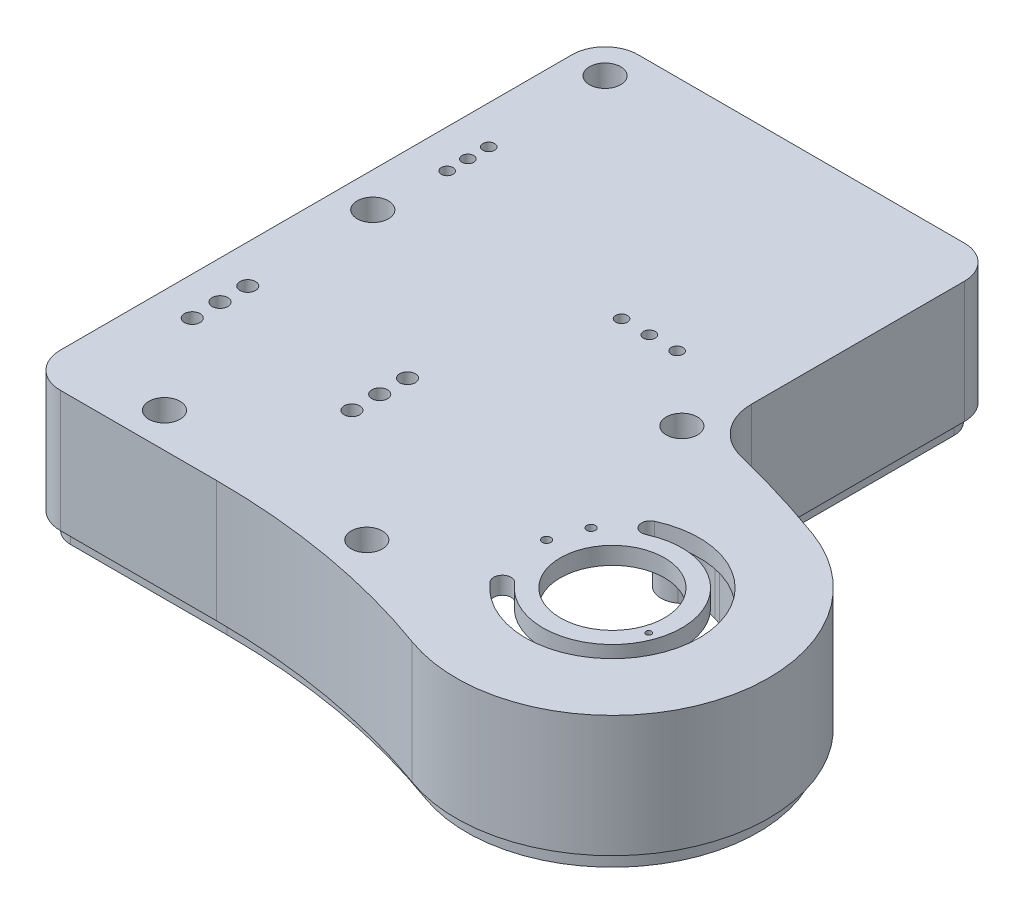
from build123d import *

# Parameters (mm, degrees)
EXTRUDE_1_DEPTH              = 35
CUT_EXTRUDE_1_DEPTH          = 30
CUT_EXTRUDE_2_REACH          = 37
SKETCH_3_R                   = 15
CUT_EXTRUDE_3_DEPTH          = 10
CUT_EXTRUDE_4_REACH          = 185.795
SKETCH_5_R                   = 15
SKETCH_5_R_2                 = 6.5
CUT_EXTRUDE_7_REACH          = 7
SKETCH_10_R                  = 1.7
SKETCH_13_R                  = 6
EXTRUDE_2_DEPTH              = 35
SKETCH_14_W                  = 2
SKETCH_14_H                  = 49.9
EXTRUDE_3_DEPTH              = 5
FILLET_1_R                   = 10
CUT_EXTRUDE_15_REACH         = 42
SKETCH_22_R                  = 1.7
SKETCH_22_R_2                = 2.25
SKETCH_23_R                  = 2.25
CUT_EXTRUDE_16_DEPTH         = 41.0000001
CUT_EXTRUDE_17_REACH         = 183.675
SKETCH_24_R                  = 1.2
HOLE_WIZARD_M4_1_D           = 4.5
HOLE_WIZARD_M4_1_DEPTH       = 40
HOLE_WIZARD_M4_1_CBORE_D     = 9
HOLE_WIZARD_M4_1_CBORE_DEPTH = 33.1
HOLE_WIZARD_M4_1_TIP         = 1.351936393
HOLE_WIZARD_M2_1_D           = 1.6
HOLE_WIZARD_M2_1_DEPTH       = 6
HOLE_WIZARD_M2_1_TIP         = 0.480688495
HOLE_WIZARD_M3_1_D           = 2.5
HOLE_WIZARD_M3_1_DEPTH       = 8.5
HOLE_WIZARD_M3_1_TIP         = 0.751075774


with BuildPart() as part:
    # 스케치1 → 보스-돌출1 (new body)
    with BuildSketch(Plane(origin=(0, 0, 0), x_dir=(1, 0, 0), z_dir=(0, 1, 0))):
        with BuildLine():
            Line((-35.5, 121.9), (10, 121.9))
            Line((10, 121.9), (58.5, 121.9))
            ThreePointArc((58.5, 121.9), (65.217514421, 119.117514421), (68, 112.4))
            Line((68, 112.4), (68, 51.135104302))
            ThreePointArc((68, 51.135104302), (71.192111556, 41.884495106), (79.409836066, 36.571082779))
            ThreePointArc((79.409836066, 36.571082779), (94.419473689, 32.440718825), (109.185841564, 27.510860028))
            ThreePointArc((109.185841564, 27.510860028), (136.08110305, -30.166214357), (78.404028665, -57.061475843))
            ThreePointArc((78.404028665, -57.061475843), (44.729635533, -48.038449398), (10, -45))
            Line((10, -45), (-35, -45))
            ThreePointArc((-35, -45), (-42.071067812, -42.071067812), (-45, -35))
            Line((-45, -35), (-45, 112.4))
            ThreePointArc((-45, 112.4), (-42.217514421, 119.117514421), (-35.5, 121.9))
        make_face()
    extrude(amount=EXTRUDE_1_DEPTH)

    # 스케치2 → 컷-돌출1 (cut)
    with BuildSketch(Plane.XZ):
        with BuildLine():
            Line((-40, 35), (-40, -112.4))
            ThreePointArc((-40, -112.4), (-38.681980515, -115.581980515), (-35.5, -116.9))
            Line((-35.5, -116.9), (58.5, -116.9))
            ThreePointArc((58.5, -116.9), (61.681980515, -115.581980515), (63, -112.4))
            Line((63, -112.4), (63, -51.135104302))
            ThreePointArc((63, -51.135104302), (67.256148741, -38.800958708), (78.213114754, -31.716408938))
            ThreePointArc((78.213114754, -31.716408938), (92.963965522, -27.657258155), (107.475740848, -22.812396924))
            ThreePointArc((107.475740848, -22.812396924), (131.382639946, 28.45611364), (80.114129382, 52.363012739))
            ThreePointArc((80.114129382, 52.363012739), (45.597876422, 43.114410632), (10, 40))
            Line((10, 40), (-35, 40))
            ThreePointArc((-35, 40), (-38.535533906, 38.535533906), (-40, 35))
        make_face()
    extrude(amount=-CUT_EXTRUDE_1_DEPTH, mode=Mode.SUBTRACT)

    # 스케치3 → 컷-돌출2 (cut, up to next)
    with BuildSketch(Plane(origin=(0, 35, 0), x_dir=(1, 0, 0), z_dir=(0, 1, 0)), mode=Mode.PRIVATE) as cut_extrude_2_sk1:
        with Locations((93.794935115, -14.775307907)):
            Circle(SKETCH_3_R)
    cut_extrude_2_tool1 = extrude(cut_extrude_2_sk1.sketch, amount=-CUT_EXTRUDE_2_REACH, mode=Mode.PRIVATE) & part.part
    add(cut_extrude_2_tool1.solids().sort_by_distance((93.794935, 35, 14.775308))[0], mode=Mode.SUBTRACT)

    # 스케치4 → 컷-돌출3 (cut)
    with BuildSketch(Plane(origin=(0, 35, 0), x_dir=(1, 0, 0), z_dir=(0, 1, 0))):
        with BuildLine():
            ThreePointArc((78.474046252, -27.631060101), (113.320855257, -19.104100186), (85.34256988, 3.350847833))
            ThreePointArc((85.34256988, 3.350847833), (82.020254758, 4.560071647), (83.229478571, 7.882386768))
            ThreePointArc((83.229478571, 7.882386768), (118.202335293, -20.186298256), (74.643824037, -30.84499815))
            ThreePointArc((74.643824037, -30.84499815), (74.95196612, -27.322918018), (78.474046252, -27.631060101))
        make_face()
    extrude(amount=-CUT_EXTRUDE_3_DEPTH, mode=Mode.SUBTRACT)

    # 스케치5 → 컷-돌출4 (cut, up to next)
    with BuildSketch(Plane.ZY.offset(45), mode=Mode.PRIVATE) as cut_extrude_4_sk1:
        Circle(SKETCH_5_R)
    cut_extrude_4_tool1 = extrude(cut_extrude_4_sk1.sketch, amount=-CUT_EXTRUDE_4_REACH, mode=Mode.PRIVATE) & part.part
    add(cut_extrude_4_tool1.solids().sort_by_distance((-45, 0, 0))[0], mode=Mode.SUBTRACT)
    # 스케치5 → 컷-돌출4 (cut, up to next)
    with BuildSketch(Plane.ZY.offset(45), mode=Mode.PRIVATE) as cut_extrude_4_sk2:
        with Locations((-71.4, 0)):
            Circle(SKETCH_5_R_2)
    cut_extrude_4_tool2 = extrude(cut_extrude_4_sk2.sketch, amount=-CUT_EXTRUDE_4_REACH, mode=Mode.PRIVATE) & part.part
    add(cut_extrude_4_tool2.solids().sort_by_distance((-45, 0, -71.4))[0], mode=Mode.SUBTRACT)

    # 스케치10 → 컷-돌출7 (cut, up to next)
    with BuildSketch(Plane.XZ.offset(-30), mode=Mode.PRIVATE) as cut_extrude_7_sk1:
        with Locations((28, -53.65)):
            Circle(SKETCH_10_R)
    cut_extrude_7_tool1 = extrude(cut_extrude_7_sk1.sketch, amount=-CUT_EXTRUDE_7_REACH, mode=Mode.PRIVATE) & part.part
    add(cut_extrude_7_tool1.solids().sort_by_distance((28, 30, -53.65))[0], mode=Mode.SUBTRACT)
    # 스케치10 → 컷-돌출7 (cut, up to next)
    with BuildSketch(Plane.XZ.offset(-30), mode=Mode.PRIVATE) as cut_extrude_7_sk2:
        with Locations((36, -53.65)):
            Circle(SKETCH_10_R)
    cut_extrude_7_tool2 = extrude(cut_extrude_7_sk2.sketch, amount=-CUT_EXTRUDE_7_REACH, mode=Mode.PRIVATE) & part.part
    add(cut_extrude_7_tool2.solids().sort_by_distance((36, 30, -53.65))[0], mode=Mode.SUBTRACT)
    # 스케치10 → 컷-돌출7 (cut, up to next)
    with BuildSketch(Plane.XZ.offset(-30), mode=Mode.PRIVATE) as cut_extrude_7_sk3:
        with Locations((44, -53.65)):
            Circle(SKETCH_10_R)
    cut_extrude_7_tool3 = extrude(cut_extrude_7_sk3.sketch, amount=-CUT_EXTRUDE_7_REACH, mode=Mode.PRIVATE) & part.part
    add(cut_extrude_7_tool3.solids().sort_by_distance((44, 30, -53.65))[0], mode=Mode.SUBTRACT)

    # 스케치13 → 보스-돌출2 (add)
    with BuildSketch(Plane.XZ.offset(-30)):
        with Locations((-15, 35)):
            Circle(SKETCH_13_R)
        with Locations((-35, -45)):
            Circle(SKETCH_13_R)
        with Locations((-35, -111.9)):
            Circle(SKETCH_13_R)
        with Locations((63.408141212, -35.605793193)):
            Circle(SKETCH_13_R)
        with Locations((46.46611731, 38.190371867)):
            Circle(SKETCH_13_R)
    extrude(amount=EXTRUDE_2_DEPTH)

    # 스케치14 → 보스-돌출3 (add)
    with BuildSketch(Plane.XZ):
        with BuildLine():
            Line((-42, 35), (-42, 15))
            Line((-42, 15), (-40, 15))
            Line((-40, 15), (-40, 35))
            ThreePointArc((-40, 35), (-38.535533906, 38.535533906), (-35, 40))
            Line((-35, 40), (10, 40))
            ThreePointArc((10, 40), (45.597876422, 43.114410632), (80.114129382, 52.363012739))
            ThreePointArc((80.114129382, 52.363012739), (131.382639946, 28.45611364), (107.475740848, -22.812396924))
            ThreePointArc((107.475740848, -22.812396924), (92.963965522, -27.657258155), (78.213114754, -31.716408938))
            ThreePointArc((78.213114754, -31.716408938), (67.256148741, -38.800958708), (63, -51.135104302))
            Line((63, -51.135104302), (63, -112.4))
            ThreePointArc((63, -112.4), (61.681980515, -115.581980515), (58.5, -116.9))
            Line((58.5, -116.9), (-35.5, -116.9))
            ThreePointArc((-35.5, -116.9), (-38.681980515, -115.581980515), (-40, -112.4))
            Line((-40, -112.4), (-40, -77.9))
            Line((-40, -77.9), (-42, -77.9))
            Line((-42, -77.9), (-42, -112.4))
            ThreePointArc((-42, -112.4), (-40.096194078, -116.996194078), (-35.5, -118.9))
            Line((-35.5, -118.9), (58.5, -118.9))
            ThreePointArc((58.5, -118.9), (63.096194078, -116.996194078), (65, -112.4))
            Line((65, -112.4), (65, -51.135104302))
            ThreePointArc((65, -51.135104302), (68.830533867, -40.034373267), (78.691803279, -33.658278474))
            ThreePointArc((78.691803279, -33.658278474), (93.546168789, -29.570642423), (108.159781134, -24.691782166))
            ThreePointArc((108.159781134, -24.691782166), (133.262025188, 29.140153927), (79.430089095, 54.24239798))
            ThreePointArc((79.430089095, 54.24239798), (45.250580066, 45.084026139), (10, 42))
            Line((10, 42), (-35, 42))
            ThreePointArc((-35, 42), (-39.949747468, 39.949747468), (-42, 35))
        make_face()
        with Locations((-41, -39.95)):
            Rectangle(SKETCH_14_W, SKETCH_14_H)
    extrude(amount=EXTRUDE_3_DEPTH)

    # 필렛1
    fillet_1_edges = [part.edges().sort_by_distance(p)[0] for p in [
        (-18.31662479, 12.5, 40),
        (-11.68337521, 12.5, 40),
        (-40, 12.5, -48.31662479),
        (-40, 12.5, -41.68337521),
        (-31.68337521, 12.5, -116.9),
        (-40, 12.5, -108.58337521),
        (69.336537978, 12.5, -36.529974875),
        (65.661312604, 12.5, -41.166658115),
        (42.366311792, 12.5, 42.571193105),
        (48.820345194, 12.5, 43.709213328),
    ]]
    fillet(fillet_1_edges, radius=FILLET_1_R)

    # 스케치22 → 컷-돌출15 (cut, up to next)
    with BuildSketch(Plane(origin=(0, 35, 0), x_dir=(1, 0, 0), z_dir=(0, 1, 0)), mode=Mode.PRIVATE) as cut_extrude_15_sk1:
        with Locations((-34, 71.4)):
            Circle(SKETCH_22_R)
    cut_extrude_15_tool1 = extrude(cut_extrude_15_sk1.sketch, amount=-CUT_EXTRUDE_15_REACH, mode=Mode.PRIVATE) & part.part
    add(cut_extrude_15_tool1.solids().sort_by_distance((-34, 35, -71.4))[0], mode=Mode.SUBTRACT)
    # 스케치22 → 컷-돌출15 (cut, up to next)
    with BuildSketch(Plane(origin=(0, 35, 0), x_dir=(1, 0, 0), z_dir=(0, 1, 0)), mode=Mode.PRIVATE) as cut_extrude_15_sk2:
        with Locations((-34, 65.4)):
            Circle(SKETCH_22_R)
    cut_extrude_15_tool2 = extrude(cut_extrude_15_sk2.sketch, amount=-CUT_EXTRUDE_15_REACH, mode=Mode.PRIVATE) & part.part
    add(cut_extrude_15_tool2.solids().sort_by_distance((-34, 35, -65.4))[0], mode=Mode.SUBTRACT)
    # 스케치22 → 컷-돌출15 (cut, up to next)
    with BuildSketch(Plane(origin=(0, 35, 0), x_dir=(1, 0, 0), z_dir=(0, 1, 0)), mode=Mode.PRIVATE) as cut_extrude_15_sk3:
        with Locations((-34, 77.4)):
            Circle(SKETCH_22_R)
    cut_extrude_15_tool3 = extrude(cut_extrude_15_sk3.sketch, amount=-CUT_EXTRUDE_15_REACH, mode=Mode.PRIVATE) & part.part
    add(cut_extrude_15_tool3.solids().sort_by_distance((-34, 35, -77.4))[0], mode=Mode.SUBTRACT)
    # 스케치22 → 컷-돌출15 (cut, up to next)
    with BuildSketch(Plane(origin=(0, 35, 0), x_dir=(1, 0, 0), z_dir=(0, 1, 0)), mode=Mode.PRIVATE) as cut_extrude_15_sk4:
        with Locations((12, 8)):
            Circle(SKETCH_22_R_2)
    cut_extrude_15_tool4 = extrude(cut_extrude_15_sk4.sketch, amount=-CUT_EXTRUDE_15_REACH, mode=Mode.PRIVATE) & part.part
    add(cut_extrude_15_tool4.solids().sort_by_distance((12, 35, -8))[0], mode=Mode.SUBTRACT)
    # 스케치22 → 컷-돌출15 (cut, up to next)
    with BuildSketch(Plane(origin=(0, 35, 0), x_dir=(1, 0, 0), z_dir=(0, 1, 0)), mode=Mode.PRIVATE) as cut_extrude_15_sk5:
        with Locations((12, 0)):
            Circle(SKETCH_22_R_2)
    cut_extrude_15_tool5 = extrude(cut_extrude_15_sk5.sketch, amount=-CUT_EXTRUDE_15_REACH, mode=Mode.PRIVATE) & part.part
    add(cut_extrude_15_tool5.solids().sort_by_distance((12, 35, 0))[0], mode=Mode.SUBTRACT)
    # 스케치22 → 컷-돌출15 (cut, up to next)
    with BuildSketch(Plane(origin=(0, 35, 0), x_dir=(1, 0, 0), z_dir=(0, 1, 0)), mode=Mode.PRIVATE) as cut_extrude_15_sk6:
        with Locations((12, -8)):
            Circle(SKETCH_22_R_2)
    cut_extrude_15_tool6 = extrude(cut_extrude_15_sk6.sketch, amount=-CUT_EXTRUDE_15_REACH, mode=Mode.PRIVATE) & part.part
    add(cut_extrude_15_tool6.solids().sort_by_distance((12, 35, 8))[0], mode=Mode.SUBTRACT)

    # 스케치23 → 컷-돌출16 (cut, through all)
    with BuildSketch(Plane(origin=(0, 35, 0), x_dir=(1, 0, 0), z_dir=(0, 1, 0))):
        with Locations((-34, -8)):
            Circle(SKETCH_23_R)
        with Locations((-34, 8)):
            Circle(SKETCH_23_R)
        with Locations((-34, 0)):
            Circle(SKETCH_23_R)
    extrude(amount=-CUT_EXTRUDE_16_DEPTH, mode=Mode.SUBTRACT)

    # 스케치24 → 컷-돌출17 (cut, up to next)
    with BuildSketch(Plane(origin=(0, 0, -121.9), x_dir=(-1, 0, 0), z_dir=(0, 0, -1)), mode=Mode.PRIVATE) as cut_extrude_17_sk1:
        with Locations((-44, 10)):
            Circle(SKETCH_24_R)
    cut_extrude_17_tool1 = extrude(cut_extrude_17_sk1.sketch, amount=-CUT_EXTRUDE_17_REACH, mode=Mode.PRIVATE) & part.part
    add(cut_extrude_17_tool1.solids().sort_by_distance((44, 10, -121.9))[0], mode=Mode.SUBTRACT)
    # 스케치24 → 컷-돌출17 (cut, up to next)
    with BuildSketch(Plane(origin=(0, 0, -121.9), x_dir=(-1, 0, 0), z_dir=(0, 0, -1)), mode=Mode.PRIVATE) as cut_extrude_17_sk2:
        with Locations((-28, 10)):
            Circle(SKETCH_24_R)
    cut_extrude_17_tool2 = extrude(cut_extrude_17_sk2.sketch, amount=-CUT_EXTRUDE_17_REACH, mode=Mode.PRIVATE) & part.part
    add(cut_extrude_17_tool2.solids().sort_by_distance((28, 10, -121.9))[0], mode=Mode.SUBTRACT)

    # M4 남비 머리 나사용 카운터보어1
    with Locations(Plane(origin=(0, 35, 0), x_dir=(1, 0, 0), z_dir=(0, 1, 0))):
        with Locations((-35, 111.9), (63.408141212, 35.605793193), (-35, 45), (-15, -35), (46.46611731, -38.190371867)):
            CounterBoreHole(HOLE_WIZARD_M4_1_D / 2, HOLE_WIZARD_M4_1_CBORE_D / 2, HOLE_WIZARD_M4_1_CBORE_DEPTH, depth=HOLE_WIZARD_M4_1_DEPTH)
            with Locations((0, 0, -(HOLE_WIZARD_M4_1_DEPTH + HOLE_WIZARD_M4_1_TIP / 2))):  # 118° drill point
                Cone(0, HOLE_WIZARD_M4_1_D / 2, HOLE_WIZARD_M4_1_TIP, mode=Mode.SUBTRACT)

    # M2 나사 구멍1
    with Locations(Plane(origin=(0, 30, 0), x_dir=(-1, 0, 0), z_dir=(0, -1, 0))):
        with Locations((-110.239555979, -20.760660416)):
            Hole(HOLE_WIZARD_M2_1_D / 2, depth=HOLE_WIZARD_M2_1_DEPTH)
            with Locations((0, 0, -(HOLE_WIZARD_M2_1_DEPTH + HOLE_WIZARD_M2_1_TIP / 2))):  # 118° drill point
                Cone(0, HOLE_WIZARD_M2_1_D / 2, HOLE_WIZARD_M2_1_TIP, mode=Mode.SUBTRACT)

    # M3 나사 구멍1
    with Locations(Plane(origin=(0, 30, 0), x_dir=(-1, 0, 0), z_dir=(0, -1, 0))):
        with Locations((-75.771490795, -2.894421794), (-72.351289362, -12.291348002)):
            Hole(HOLE_WIZARD_M3_1_D / 2, depth=HOLE_WIZARD_M3_1_DEPTH)
            with Locations((0, 0, -(HOLE_WIZARD_M3_1_DEPTH + HOLE_WIZARD_M3_1_TIP / 2))):  # 118° drill point
                Cone(0, HOLE_WIZARD_M3_1_D / 2, HOLE_WIZARD_M3_1_TIP, mode=Mode.SUBTRACT)


solid = part.part
